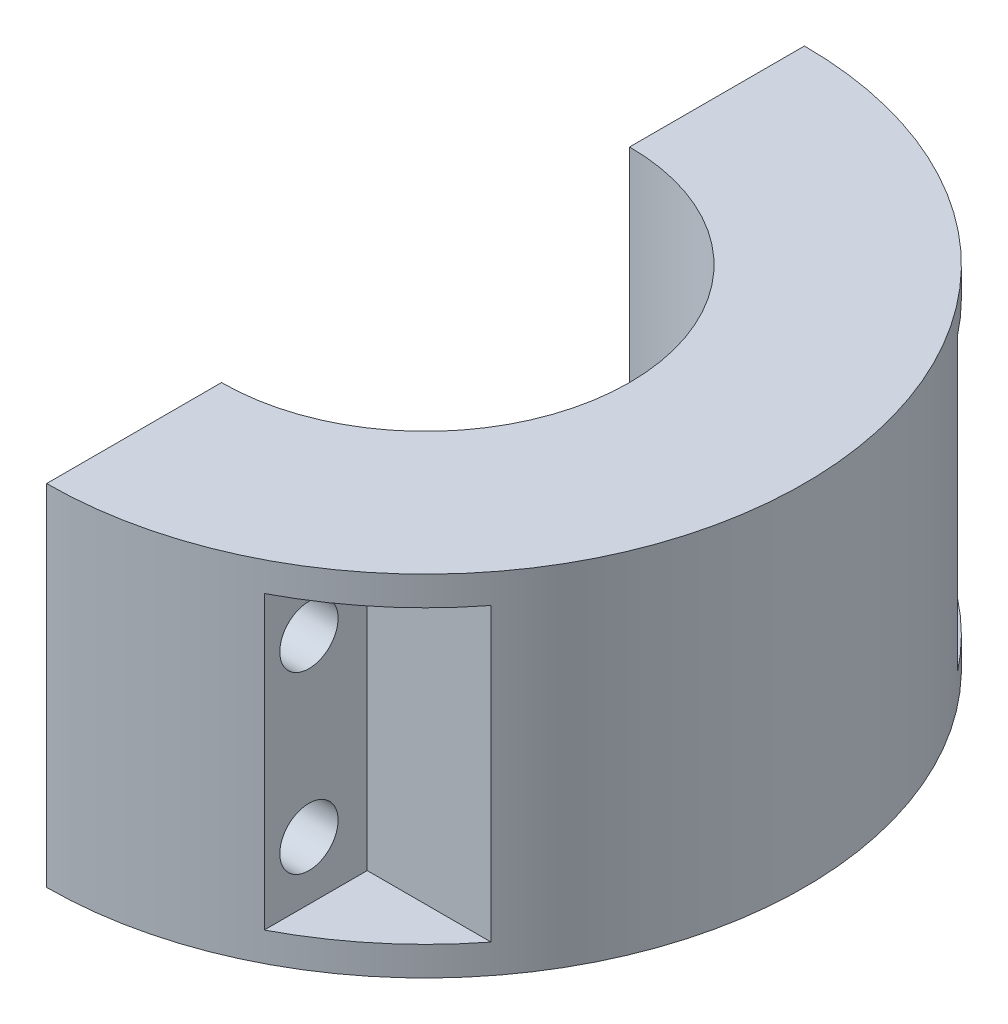
from build123d import *

# Parameters (mm, degrees)
BOSS_EXTRUDE1_DEPTH = 76.2
SKETCH2_R           = 6.35
CUT_EXTRUDE1_DEPTH  = 83.55
SKETCH3_W           = 25.4
SKETCH3_H           = 63.5
CUT_EXTRUDE2_DEPTH  = 45.4500001


with BuildPart() as part:
    # Sketch1 → Boss-Extrude1 (new body)
    with BuildSketch(Plane(origin=(0, 0, 0), x_dir=(1, 0, 0), z_dir=(0, 1, 0))):
        with BuildLine():
            Line((0, 82.55), (0, 44.45))
            ThreePointArc((0, 44.45), (44.45, 0), (0, -44.45))
            Line((0, -44.45), (0, -82.55))
            ThreePointArc((0, -82.55), (82.55, 0), (0, 82.55))
        make_face()
    extrude(amount=BOSS_EXTRUDE1_DEPTH)

    # Sketch2 → Cut-Extrude1 (cut, through all)
    with BuildSketch(Plane.ZY):
        with Locations((-63.5, 57.15)):
            Circle(SKETCH2_R)
        with Locations((-63.5, 19.05)):
            Circle(SKETCH2_R)
        with Locations((63.5, 19.05)):
            Circle(SKETCH2_R)
        with Locations((63.5, 57.15)):
            Circle(SKETCH2_R)
    extrude(amount=-CUT_EXTRUDE1_DEPTH, mode=Mode.SUBTRACT)

    # Sketch3 → Cut-Extrude2 (cut, through all)
    with BuildSketch(Plane.ZY.offset(-38.1)):
        with Locations((63.5, 38.1)):
            Rectangle(SKETCH3_W, SKETCH3_H)
        with Locations((-63.5, 38.1)):
            Rectangle(SKETCH3_W, SKETCH3_H)
    extrude(amount=-CUT_EXTRUDE2_DEPTH, mode=Mode.SUBTRACT)


solid = part.part
